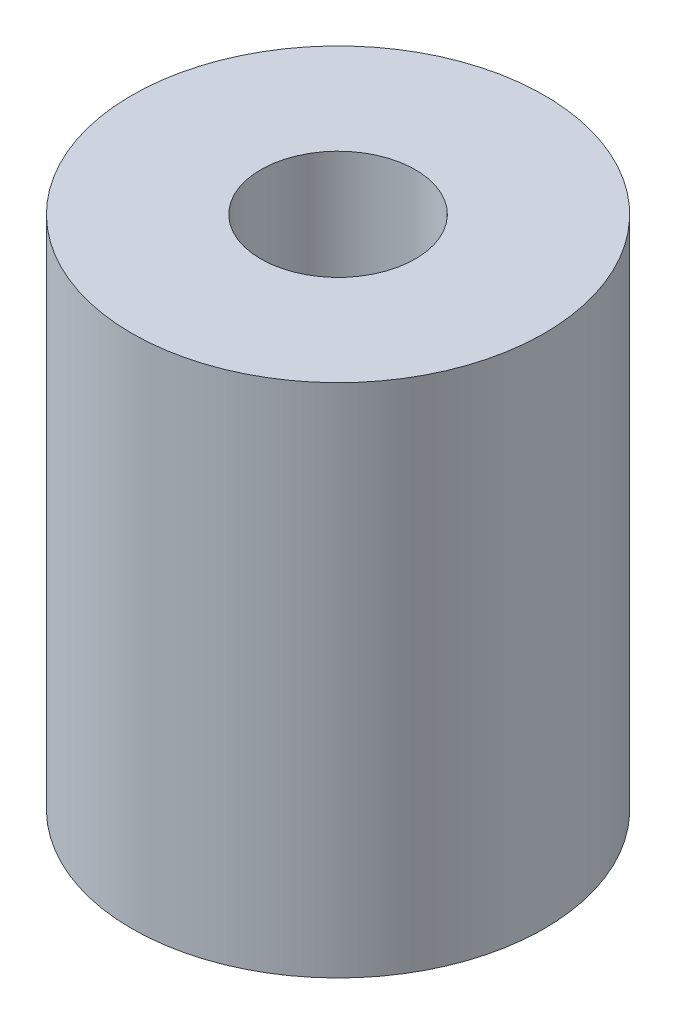
from build123d import *

# Parameters (mm, degrees)
SKETCH1_R           = 4
SKETCH1_R_2         = 1.5
BOSS_EXTRUDE1_DEPTH = 10


with BuildPart() as part:
    # Sketch1 → Boss-Extrude1 (new body)
    with BuildSketch(Plane(origin=(0, 0, 0), x_dir=(1, 0, 0), z_dir=(0, 1, 0))):
        Circle(SKETCH1_R)
        Circle(SKETCH1_R_2, mode=Mode.SUBTRACT)
    extrude(amount=BOSS_EXTRUDE1_DEPTH)


solid = part.part
